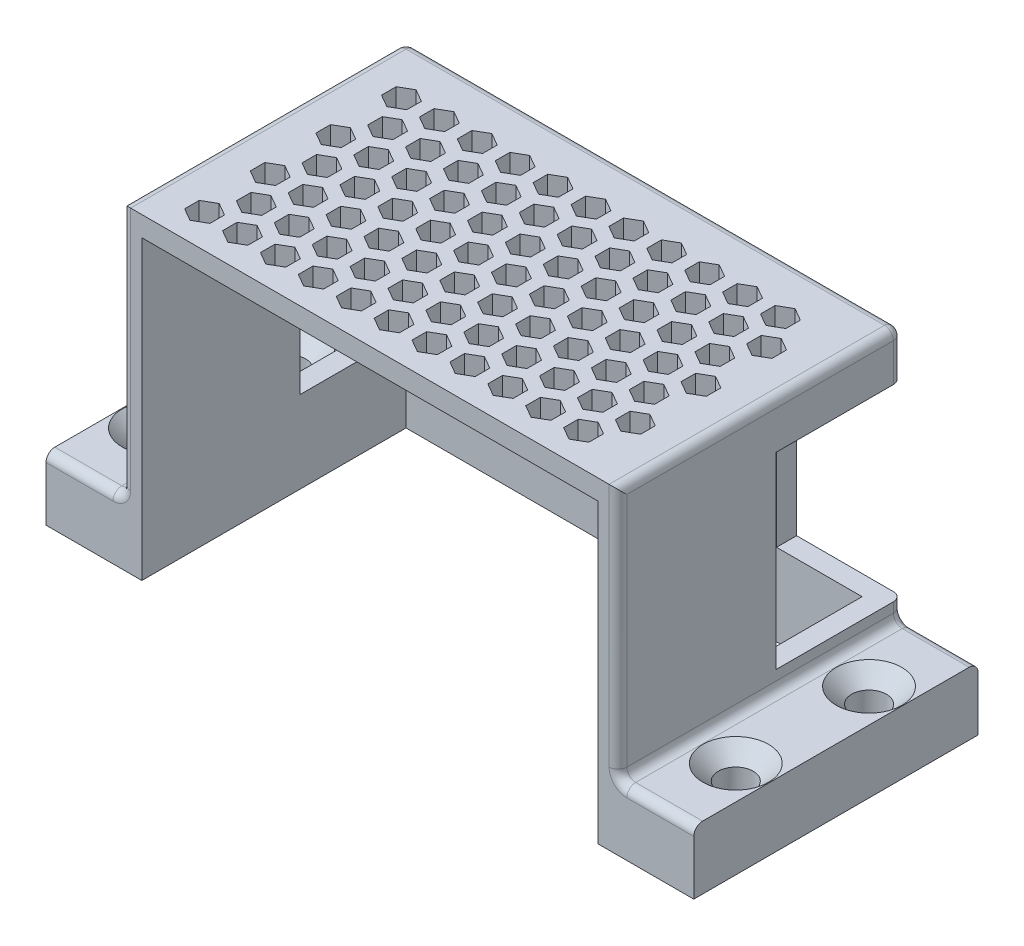
from build123d import *

# Parameters (mm, degrees)
SKETCH1_W                                       = 78.55
SKETCH1_H                                       = 45
BOSS_EXTRUDE1_DEPTH                             = 50.175
SHELL1_T                                        = -3.175
SKETCH2_W                                       = 45
SKETCH2_H                                       = 10
BOSS_EXTRUDE2_DEPTH                             = 12
FILLET1_R                                       = 1.4
FILLET2_R                                       = 1.4
CUT_EXTRUDE1_DEPTH                              = 12
FILLET3_R                                       = 1.4
CSK_FOR_M5_FLAT_HEAD_MACHINE_SCREW1_D           = 5.5
CSK_FOR_M5_FLAT_HEAD_MACHINE_SCREW1_DEPTH       = 10
CSK_FOR_M5_FLAT_HEAD_MACHINE_SCREW1_CSINK_D     = 10.4
CSK_FOR_M5_FLAT_HEAD_MACHINE_SCREW1_CSINK_ANGLE = 90
SKETCH8_W                                       = 27.406669758
SKETCH8_H                                       = 29.775147392
CUT_EXTRUDE2_DEPTH                              = 20


with BuildPart() as part:
    # Sketch1 → Boss-Extrude1 (new body)
    with BuildSketch(Plane(origin=(0, 0, 0), x_dir=(1, 0, 0), z_dir=(0, 1, 0))):
        Rectangle(SKETCH1_W, SKETCH1_H)
    extrude(amount=BOSS_EXTRUDE1_DEPTH)

    # Shell1
    shell1_openings = [part.faces().sort_by_distance(p)[0] for p in [
        (0, 0, 0),
        (0, 25.0875, 22.5),
    ]]
    offset(amount=SHELL1_T, openings=shell1_openings, kind=Kind.INTERSECTION)

    # Sketch2 → Boss-Extrude2 (add)
    with BuildSketch(Plane(origin=(39.275, 0, 0), x_dir=(0, 0, -1), z_dir=(1, 0, 0))):
        with Locations((0, 5)):
            Rectangle(SKETCH2_W, SKETCH2_H)
    boss_extrude2 = extrude(amount=BOSS_EXTRUDE2_DEPTH)

    # Fillet1
    fillet1_edges = [part.edges().sort_by_distance(p)[0] for p in [
        (39.275, 10, 0),
    ]]
    fillet(fillet1_edges, radius=FILLET1_R)

    # Mirror1: Boss-Extrude2 across plane
    add(boss_extrude2.mirror(Plane(origin=(0, 0, 0), x_dir=(0, 0, 1), z_dir=(1, 0, 0))))

    # Fillet2
    fillet2_edges = [part.edges().sort_by_distance(p)[0] for p in [
        (-39.275, 10, 0),
    ]]
    fillet(fillet2_edges, radius=FILLET2_R)

    # Sketch3 → Cut-Extrude1 (cut)
    with BuildSketch(Plane(origin=(0, 50.175, 0), x_dir=(1, 0, 0), z_dir=(0, 1, 0))):
        Polygon((-20.5, 7.649745962), (-20.5, 9.959147039), (-22.5, 11.113847577), (-24.5, 9.959147039), (-24.5, 7.649745962), (-22.5, 6.495045424), align=None)
        Polygon((-26.5, 7.649745962), (-26.5, 9.959147039), (-28.5, 11.113847577), (-30.5, 9.959147039), (-30.5, 7.649745962), (-28.5, 6.495045424), align=None)
        Polygon((-29.5, 12.845898385), (-29.5, 15.155299462), (-31.5, 16.31), (-33.5, 15.155299462), (-33.5, 12.845898385), (-31.5, 11.691197846), align=None)
        Polygon((-23.5, 12.845898385), (-23.5, 15.155299462), (-25.5, 16.31), (-27.5, 15.155299462), (-27.5, 12.845898385), (-25.5, 11.691197846), align=None)
        Polygon((-14.5, 7.649745962), (-14.5, 9.959147039), (-16.5, 11.113847577), (-18.5, 9.959147039), (-18.5, 7.649745962), (-16.5, 6.495045424), align=None)
        Polygon((-17.5, 12.845898385), (-17.5, 15.155299462), (-19.5, 16.31), (-21.5, 15.155299462), (-21.5, 12.845898385), (-19.5, 11.691197846), align=None)
        Polygon((-8.5, 7.649745962), (-8.5, 9.959147039), (-10.5, 11.113847577), (-12.5, 9.959147039), (-12.5, 7.649745962), (-10.5, 6.495045424), align=None)
        Polygon((-11.5, 12.845898385), (-11.5, 15.155299462), (-13.5, 16.31), (-15.5, 15.155299462), (-15.5, 12.845898385), (-13.5, 11.691197846), align=None)
        Polygon((-2.5, 7.649745962), (-2.5, 9.959147039), (-4.5, 11.113847577), (-6.5, 9.959147039), (-6.5, 7.649745962), (-4.5, 6.495045424), align=None)
        Polygon((-5.5, 12.845898385), (-5.5, 15.155299462), (-7.5, 16.31), (-9.5, 15.155299462), (-9.5, 12.845898385), (-7.5, 11.691197846), align=None)
        Polygon((3.5, 7.649745962), (3.5, 9.959147039), (1.5, 11.113847577), (-0.5, 9.959147039), (-0.5, 7.649745962), (1.5, 6.495045424), align=None)
        Polygon((0.5, 12.845898385), (0.5, 15.155299462), (-1.5, 16.31), (-3.5, 15.155299462), (-3.5, 12.845898385), (-1.5, 11.691197846), align=None)
        Polygon((9.5, 7.649745962), (9.5, 9.959147039), (7.5, 11.113847577), (5.5, 9.959147039), (5.5, 7.649745962), (7.5, 6.495045424), align=None)
        Polygon((6.5, 12.845898385), (6.5, 15.155299462), (4.5, 16.31), (2.5, 15.155299462), (2.5, 12.845898385), (4.5, 11.691197846), align=None)
        Polygon((15.5, 7.649745962), (15.5, 9.959147039), (13.5, 11.113847577), (11.5, 9.959147039), (11.5, 7.649745962), (13.5, 6.495045424), align=None)
        Polygon((12.5, 12.845898385), (12.5, 15.155299462), (10.5, 16.31), (8.5, 15.155299462), (8.5, 12.845898385), (10.5, 11.691197846), align=None)
        Polygon((21.5, 7.649745962), (21.5, 9.959147039), (19.5, 11.113847577), (17.5, 9.959147039), (17.5, 7.649745962), (19.5, 6.495045424), align=None)
        Polygon((18.5, 12.845898385), (18.5, 15.155299462), (16.5, 16.31), (14.5, 15.155299462), (14.5, 12.845898385), (16.5, 11.691197846), align=None)
        Polygon((27.5, 7.649745962), (27.5, 9.959147039), (25.5, 11.113847577), (23.5, 9.959147039), (23.5, 7.649745962), (25.5, 6.495045424), align=None)
        Polygon((24.5, 12.845898385), (24.5, 15.155299462), (22.5, 16.31), (20.5, 15.155299462), (20.5, 12.845898385), (22.5, 11.691197846), align=None)
        Polygon((33.5, 7.649745962), (33.5, 9.959147039), (31.5, 11.113847577), (29.5, 9.959147039), (29.5, 7.649745962), (31.5, 6.495045424), align=None)
        Polygon((30.5, 12.845898385), (30.5, 15.155299462), (28.5, 16.31), (26.5, 15.155299462), (26.5, 12.845898385), (28.5, 11.691197846), align=None)
        Polygon((-20.5, -2.740254038), (-20.5, -0.430852961), (-22.5, 0.723847577), (-24.5, -0.430852961), (-24.5, -2.740254038), (-22.5, -3.894954576), align=None)
        Polygon((-23.5, 2.455898385), (-23.5, 4.765299462), (-25.5, 5.92), (-27.5, 4.765299462), (-27.5, 2.455898385), (-25.5, 1.301197846), align=None)
        Polygon((-14.5, -2.740254038), (-14.5, -0.430852961), (-16.5, 0.723847577), (-18.5, -0.430852961), (-18.5, -2.740254038), (-16.5, -3.894954576), align=None)
        Polygon((-17.5, 2.455898385), (-17.5, 4.765299462), (-19.5, 5.92), (-21.5, 4.765299462), (-21.5, 2.455898385), (-19.5, 1.301197846), align=None)
        Polygon((-8.5, -2.740254038), (-8.5, -0.430852961), (-10.5, 0.723847577), (-12.5, -0.430852961), (-12.5, -2.740254038), (-10.5, -3.894954576), align=None)
        Polygon((-11.5, 2.455898385), (-11.5, 4.765299462), (-13.5, 5.92), (-15.5, 4.765299462), (-15.5, 2.455898385), (-13.5, 1.301197846), align=None)
        Polygon((-2.5, -2.740254038), (-2.5, -0.430852961), (-4.5, 0.723847577), (-6.5, -0.430852961), (-6.5, -2.740254038), (-4.5, -3.894954576), align=None)
        Polygon((-5.5, 2.455898385), (-5.5, 4.765299462), (-7.5, 5.92), (-9.5, 4.765299462), (-9.5, 2.455898385), (-7.5, 1.301197846), align=None)
        Polygon((3.5, -2.740254038), (3.5, -0.430852961), (1.5, 0.723847577), (-0.5, -0.430852961), (-0.5, -2.740254038), (1.5, -3.894954576), align=None)
        Polygon((0.5, 2.455898385), (0.5, 4.765299462), (-1.5, 5.92), (-3.5, 4.765299462), (-3.5, 2.455898385), (-1.5, 1.301197846), align=None)
        Polygon((9.5, -2.740254038), (9.5, -0.430852961), (7.5, 0.723847577), (5.5, -0.430852961), (5.5, -2.740254038), (7.5, -3.894954576), align=None)
        Polygon((6.5, 2.455898385), (6.5, 4.765299462), (4.5, 5.92), (2.5, 4.765299462), (2.5, 2.455898385), (4.5, 1.301197846), align=None)
        Polygon((15.5, -2.740254038), (15.5, -0.430852961), (13.5, 0.723847577), (11.5, -0.430852961), (11.5, -2.740254038), (13.5, -3.894954576), align=None)
        Polygon((12.5, 2.455898385), (12.5, 4.765299462), (10.5, 5.92), (8.5, 4.765299462), (8.5, 2.455898385), (10.5, 1.301197846), align=None)
        Polygon((21.5, -2.740254038), (21.5, -0.430852961), (19.5, 0.723847577), (17.5, -0.430852961), (17.5, -2.740254038), (19.5, -3.894954576), align=None)
        Polygon((18.5, 2.455898385), (18.5, 4.765299462), (16.5, 5.92), (14.5, 4.765299462), (14.5, 2.455898385), (16.5, 1.301197846), align=None)
        Polygon((27.5, -2.740254038), (27.5, -0.430852961), (25.5, 0.723847577), (23.5, -0.430852961), (23.5, -2.740254038), (25.5, -3.894954576), align=None)
        Polygon((24.5, 2.455898385), (24.5, 4.765299462), (22.5, 5.92), (20.5, 4.765299462), (20.5, 2.455898385), (22.5, 1.301197846), align=None)
        Polygon((33.5, -2.740254038), (33.5, -0.430852961), (31.5, 0.723847577), (29.5, -0.430852961), (29.5, -2.740254038), (31.5, -3.894954576), align=None)
        Polygon((30.5, 2.455898385), (30.5, 4.765299462), (28.5, 5.92), (26.5, 4.765299462), (26.5, 2.455898385), (28.5, 1.301197846), align=None)
        Polygon((-20.5, -13.130254038), (-20.5, -10.820852961), (-22.5, -9.666152423), (-24.5, -10.820852961), (-24.5, -13.130254038), (-22.5, -14.284954576), align=None)
        Polygon((-23.5, -7.934101615), (-23.5, -5.624700538), (-25.5, -4.47), (-27.5, -5.624700538), (-27.5, -7.934101615), (-25.5, -9.088802154), align=None)
        Polygon((-14.5, -13.130254038), (-14.5, -10.820852961), (-16.5, -9.666152423), (-18.5, -10.820852961), (-18.5, -13.130254038), (-16.5, -14.284954576), align=None)
        Polygon((-17.5, -7.934101615), (-17.5, -5.624700538), (-19.5, -4.47), (-21.5, -5.624700538), (-21.5, -7.934101615), (-19.5, -9.088802154), align=None)
        Polygon((-8.5, -13.130254038), (-8.5, -10.820852961), (-10.5, -9.666152423), (-12.5, -10.820852961), (-12.5, -13.130254038), (-10.5, -14.284954576), align=None)
        Polygon((-11.5, -7.934101615), (-11.5, -5.624700538), (-13.5, -4.47), (-15.5, -5.624700538), (-15.5, -7.934101615), (-13.5, -9.088802154), align=None)
        Polygon((-2.5, -13.130254038), (-2.5, -10.820852961), (-4.5, -9.666152423), (-6.5, -10.820852961), (-6.5, -13.130254038), (-4.5, -14.284954576), align=None)
        Polygon((-5.5, -7.934101615), (-5.5, -5.624700538), (-7.5, -4.47), (-9.5, -5.624700538), (-9.5, -7.934101615), (-7.5, -9.088802154), align=None)
        Polygon((3.5, -13.130254038), (3.5, -10.820852961), (1.5, -9.666152423), (-0.5, -10.820852961), (-0.5, -13.130254038), (1.5, -14.284954576), align=None)
        Polygon((0.5, -7.934101615), (0.5, -5.624700538), (-1.5, -4.47), (-3.5, -5.624700538), (-3.5, -7.934101615), (-1.5, -9.088802154), align=None)
        Polygon((9.5, -13.130254038), (9.5, -10.820852961), (7.5, -9.666152423), (5.5, -10.820852961), (5.5, -13.130254038), (7.5, -14.284954576), align=None)
        Polygon((6.5, -7.934101615), (6.5, -5.624700538), (4.5, -4.47), (2.5, -5.624700538), (2.5, -7.934101615), (4.5, -9.088802154), align=None)
        Polygon((15.5, -13.130254038), (15.5, -10.820852961), (13.5, -9.666152423), (11.5, -10.820852961), (11.5, -13.130254038), (13.5, -14.284954576), align=None)
        Polygon((12.5, -7.934101615), (12.5, -5.624700538), (10.5, -4.47), (8.5, -5.624700538), (8.5, -7.934101615), (10.5, -9.088802154), align=None)
        Polygon((21.5, -13.130254038), (21.5, -10.820852961), (19.5, -9.666152423), (17.5, -10.820852961), (17.5, -13.130254038), (19.5, -14.284954576), align=None)
        Polygon((18.5, -7.934101615), (18.5, -5.624700538), (16.5, -4.47), (14.5, -5.624700538), (14.5, -7.934101615), (16.5, -9.088802154), align=None)
        Polygon((27.5, -13.130254038), (27.5, -10.820852961), (25.5, -9.666152423), (23.5, -10.820852961), (23.5, -13.130254038), (25.5, -14.284954576), align=None)
        Polygon((24.5, -7.934101615), (24.5, -5.624700538), (22.5, -4.47), (20.5, -5.624700538), (20.5, -7.934101615), (22.5, -9.088802154), align=None)
        Polygon((33.5, -13.130254038), (33.5, -10.820852961), (31.5, -9.666152423), (29.5, -10.820852961), (29.5, -13.130254038), (31.5, -14.284954576), align=None)
        Polygon((30.5, -7.934101615), (30.5, -5.624700538), (28.5, -4.47), (26.5, -5.624700538), (26.5, -7.934101615), (28.5, -9.088802154), align=None)
        Polygon((-23.5, -18.324101615), (-23.5, -16.014700538), (-25.5, -14.86), (-27.5, -16.014700538), (-27.5, -18.324101615), (-25.5, -19.478802154), align=None)
        Polygon((-17.5, -18.324101615), (-17.5, -16.014700538), (-19.5, -14.86), (-21.5, -16.014700538), (-21.5, -18.324101615), (-19.5, -19.478802154), align=None)
        Polygon((-11.5, -18.324101615), (-11.5, -16.014700538), (-13.5, -14.86), (-15.5, -16.014700538), (-15.5, -18.324101615), (-13.5, -19.478802154), align=None)
        Polygon((-5.5, -18.324101615), (-5.5, -16.014700538), (-7.5, -14.86), (-9.5, -16.014700538), (-9.5, -18.324101615), (-7.5, -19.478802154), align=None)
        Polygon((0.5, -18.324101615), (0.5, -16.014700538), (-1.5, -14.86), (-3.5, -16.014700538), (-3.5, -18.324101615), (-1.5, -19.478802154), align=None)
        Polygon((6.5, -18.324101615), (6.5, -16.014700538), (4.5, -14.86), (2.5, -16.014700538), (2.5, -18.324101615), (4.5, -19.478802154), align=None)
        Polygon((12.5, -18.324101615), (12.5, -16.014700538), (10.5, -14.86), (8.5, -16.014700538), (8.5, -18.324101615), (10.5, -19.478802154), align=None)
        Polygon((18.5, -18.324101615), (18.5, -16.014700538), (16.5, -14.86), (14.5, -16.014700538), (14.5, -18.324101615), (16.5, -19.478802154), align=None)
        Polygon((24.5, -18.324101615), (24.5, -16.014700538), (22.5, -14.86), (20.5, -16.014700538), (20.5, -18.324101615), (22.5, -19.478802154), align=None)
        Polygon((30.5, -18.324101615), (30.5, -16.014700538), (28.5, -14.86), (26.5, -16.014700538), (26.5, -18.324101615), (28.5, -19.478802154), align=None)
        Polygon((-26.5, -2.740254038), (-26.5, -0.430852961), (-28.5, 0.723847577), (-30.5, -0.430852961), (-30.5, -2.740254038), (-28.5, -3.894954576), align=None)
        Polygon((-29.5, 2.455898385), (-29.5, 4.765299462), (-31.5, 5.92), (-33.5, 4.765299462), (-33.5, 2.455898385), (-31.5, 1.301197846), align=None)
        Polygon((-26.5, -13.130254038), (-26.5, -10.820852961), (-28.5, -9.666152423), (-30.5, -10.820852961), (-30.5, -13.130254038), (-28.5, -14.284954576), align=None)
        Polygon((-29.5, -7.934101615), (-29.5, -5.624700538), (-31.5, -4.47), (-33.5, -5.624700538), (-33.5, -7.934101615), (-31.5, -9.088802154), align=None)
        Polygon((-29.5, -18.324101615), (-29.5, -16.014700538), (-31.5, -14.86), (-33.5, -16.014700538), (-33.5, -18.324101615), (-31.5, -19.478802154), align=None)
    extrude(amount=-CUT_EXTRUDE1_DEPTH, mode=Mode.SUBTRACT)

    # Fillet3
    fillet3_edges = [part.edges().sort_by_distance(p)[0] for p in [
        (39.275, 50.175, 0),
        (0, 50.175, -22.5),
        (45.975, 10, 22.5),
        (45.975, 10, -22.5),
        (39.685050506, 10.410050506, 22.5),
        (39.685050506, 10.410050506, -22.5),
        (-45.975, 10, 22.5),
        (-45.975, 10, -22.5),
        (-39.275, 50.175, 0),
        (-39.685050506, 10.410050506, 22.5),
        (-39.685050506, 10.410050506, -22.5),
        (-39.275, 30.7875, -22.5),
        (39.275, 30.7875, -22.5),
        (39.275, 30.7875, 22.5),
        (-39.275, 30.7875, 22.5),
    ]]
    fillet(fillet3_edges, radius=FILLET3_R)

    # CSK for M5 Flat Head Machine Screw1
    with Locations(Plane(origin=(0, 10, 0), x_dir=(1, 0, 0), z_dir=(0, 1, 0))):
        with Locations((-45.975, -10.55), (-45.975, 10.55)):
            csk_for_m5_flat_head_machine_screw1 = CounterSinkHole(CSK_FOR_M5_FLAT_HEAD_MACHINE_SCREW1_D / 2, CSK_FOR_M5_FLAT_HEAD_MACHINE_SCREW1_CSINK_D / 2, depth=CSK_FOR_M5_FLAT_HEAD_MACHINE_SCREW1_DEPTH, counter_sink_angle=CSK_FOR_M5_FLAT_HEAD_MACHINE_SCREW1_CSINK_ANGLE)

    # Mirror2: CSK for M5 Flat Head Machine Screw1 across plane
    add(csk_for_m5_flat_head_machine_screw1.mirror(Plane(origin=(0, 0, 0), x_dir=(0, 0, 1), z_dir=(1, 0, 0))), mode=Mode.SUBTRACT)

    # Sketch8 → Cut-Extrude2 (cut)
    with BuildSketch(Plane(origin=(0, 0, -22.5), x_dir=(-1, 0, 0), z_dir=(0, 0, -1))):
        with Locations((-36.260264722, 27.859529607)):
            Rectangle(SKETCH8_W, SKETCH8_H)
    cut_extrude2 = extrude(amount=-CUT_EXTRUDE2_DEPTH, mode=Mode.SUBTRACT)

    # Mirror3: Cut-Extrude2 across plane
    add(cut_extrude2.mirror(Plane(origin=(0, 0, 0), x_dir=(0, 0, 1), z_dir=(1, 0, 0))), mode=Mode.SUBTRACT)


solid = part.part
